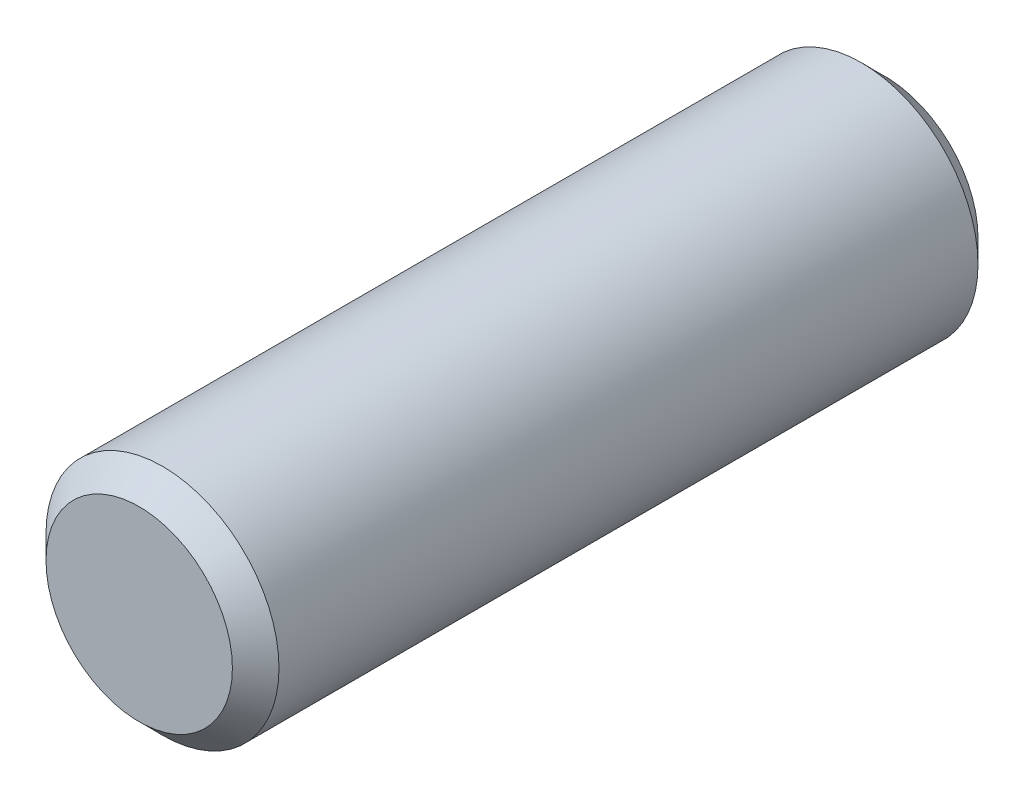
from build123d import *

# Parameters (mm, degrees)
SKETCH1_R           = 2.5
BOSS_EXTRUDE1_DEPTH = 8
CHAMFER1_SIZE       = 0.5


with BuildPart() as part:
    # Sketch1 → Boss-Extrude1 (new body, symmetric)
    with BuildSketch(Plane.XY):
        Circle(SKETCH1_R)
    extrude(amount=BOSS_EXTRUDE1_DEPTH, both=True)

    # Chamfer1
    chamfer1_edges = [part.edges().sort_by_distance(p)[0] for p in [
        (-2.5, 0, -8),
        (-2.5, 0, 8),
    ]]
    chamfer(chamfer1_edges, length=CHAMFER1_SIZE)


solid = part.part
